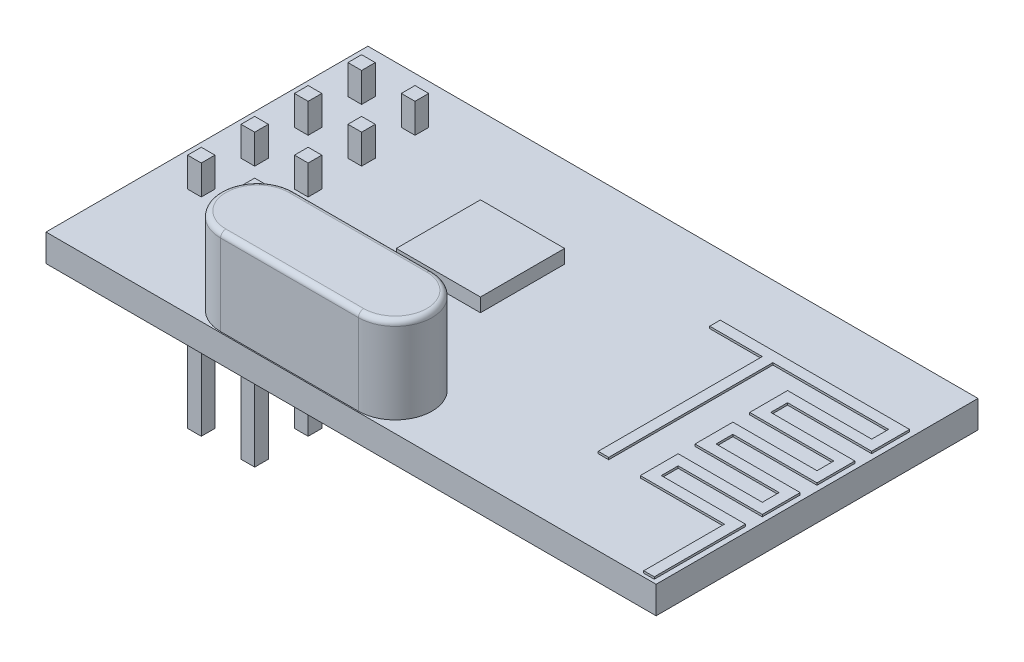
from build123d import *

# Parameters (mm, degrees)
SKETCH1_W                = 29
SKETCH1_H                = 15.3
BOSS_EXTRUDE1_DEPTH      = 1.3
BOSS_EXTRUDE2_DEPTH      = 4.1
SKETCH3_W                = 0.65
SKETCH3_H                = 0.65
BOSS_EXTRUDE3_DEPTH      = 1.4
BOSS_EXTRUDE3_DEPTH_BACK = 10
SKETCH4_W                = 4.99
SKETCH4_H                = 10.07
BOSS_EXTRUDE4_DEPTH      = 2.54
SKETCH5_W                = 4
SKETCH5_H                = 4
BOSS_EXTRUDE5_DEPTH      = 0.65
FILLET1_R                = 0.25
CHAMFER1_SIZE            = 0.15
BOSS_EXTRUDE6_DEPTH      = 0.1


with BuildPart() as part:
    # Sketch1 → Boss-Extrude1 (new body)
    with BuildSketch(Plane(origin=(0, 0, 0), x_dir=(1, 0, 0), z_dir=(0, 1, 0))):
        with Locations((-0.556382979, -0.474734043)):
            Rectangle(SKETCH1_W, SKETCH1_H)
    extrude(amount=BOSS_EXTRUDE1_DEPTH)

    # Sketch2 → Boss-Extrude2 (add)
    with BuildSketch(Plane(origin=(0, 1.3, 0), x_dir=(1, 0, 0), z_dir=(0, 1, 0))):
        with BuildLine():
            Line((-6.806382979, -4.574734043), (-0.256382979, -4.574734043))
            ThreePointArc((-0.256382979, -4.574734043), (1.493617021, -6.324734043), (-0.256382979, -8.074734043))
            Line((-0.256382979, -8.074734043), (-6.806382979, -8.074734043))
            ThreePointArc((-6.806382979, -8.074734043), (-8.556382979, -6.324734043), (-6.806382979, -4.574734043))
        make_face()
    extrude(amount=BOSS_EXTRUDE2_DEPTH)

    # Sketch3 → Boss-Extrude3 (add, two sides)
    with BuildSketch(Plane(origin=(0, 1.3, 0), x_dir=(1, 0, 0), z_dir=(0, 1, 0))) as boss_extrude3_sk:
        with Locations((-13.131382979, 4.950265957)):
            Rectangle(SKETCH3_W, SKETCH3_H)
        with Locations((-10.591382979, 4.950265957)):
            Rectangle(SKETCH3_W, SKETCH3_H)
        with Locations((-10.591382979, 2.410265957)):
            Rectangle(SKETCH3_W, SKETCH3_H)
        with Locations((-10.591382979, -0.129734043)):
            Rectangle(SKETCH3_W, SKETCH3_H)
        with Locations((-10.591382979, -2.669734043)):
            Rectangle(SKETCH3_W, SKETCH3_H)
        with Locations((-13.131382979, 2.410265957)):
            Rectangle(SKETCH3_W, SKETCH3_H)
        with Locations((-13.131382979, -0.129734043)):
            Rectangle(SKETCH3_W, SKETCH3_H)
        with Locations((-13.131382979, -2.669734043)):
            Rectangle(SKETCH3_W, SKETCH3_H)
    extrude(amount=BOSS_EXTRUDE3_DEPTH)
    extrude(boss_extrude3_sk.sketch, amount=-BOSS_EXTRUDE3_DEPTH_BACK)

    # Sketch4 → Boss-Extrude4 (add)
    with BuildSketch(Plane.XZ):
        with Locations((-11.861382979, -1.140265957)):
            Rectangle(SKETCH4_W, SKETCH4_H)
    extrude(amount=BOSS_EXTRUDE4_DEPTH)

    # Sketch5 → Boss-Extrude5 (add)
    with BuildSketch(Plane(origin=(0, 1.3, 0), x_dir=(1, 0, 0), z_dir=(0, 1, 0))):
        with Locations((-3.406382979, 0.875265957)):
            Rectangle(SKETCH5_W, SKETCH5_H)
    extrude(amount=BOSS_EXTRUDE5_DEPTH)

    # Fillet1
    fillet1_edges = [part.edges().sort_by_distance(p)[0] for p in [
        (-8.556382979, 5.4, 6.324734043),
        (-3.531382979, 5.4, 8.074734043),
        (1.493617021, 5.4, 6.324734043),
        (-3.531382979, 5.4, 4.574734043),
    ]]
    fillet(fillet1_edges, radius=FILLET1_R)

    # Chamfer1
    chamfer1_edges = [part.edges().sort_by_distance(p)[0] for p in [
        (-10.591382979, -8.7, 2.344734043),
        (-10.266382979, -8.7, 2.669734043),
        (-10.591382979, -8.7, 2.994734043),
        (-10.916382979, -8.7, 2.669734043),
        (-13.131382979, -8.7, -2.735265957),
        (-12.806382979, -8.7, -2.410265957),
        (-13.131382979, -8.7, -2.085265957),
        (-13.456382979, -8.7, -2.410265957),
        (-13.131382979, -8.7, -0.195265957),
        (-12.806382979, -8.7, 0.129734043),
        (-13.131382979, -8.7, 0.454734043),
        (-13.456382979, -8.7, 0.129734043),
        (-13.131382979, -8.7, 2.344734043),
        (-12.806382979, -8.7, 2.669734043),
        (-13.131382979, -8.7, 2.994734043),
        (-13.456382979, -8.7, 2.669734043),
        (-13.456382979, -8.7, -4.950265957),
        (-13.131382979, -8.7, -5.275265957),
        (-12.806382979, -8.7, -4.950265957),
        (-13.131382979, -8.7, -4.625265957),
        (-10.591382979, -8.7, -5.275265957),
        (-10.266382979, -8.7, -4.950265957),
        (-10.591382979, -8.7, -4.625265957),
        (-10.916382979, -8.7, -4.950265957),
        (-10.591382979, -8.7, -2.735265957),
        (-10.266382979, -8.7, -2.410265957),
        (-10.591382979, -8.7, -2.085265957),
        (-10.916382979, -8.7, -2.410265957),
        (-10.591382979, -8.7, -0.195265957),
        (-10.266382979, -8.7, 0.129734043),
        (-10.591382979, -8.7, 0.454734043),
        (-10.916382979, -8.7, 0.129734043),
    ]]
    chamfer(chamfer1_edges, length=CHAMFER1_SIZE)

    # Sketch6 → Boss-Extrude6 (add)
    with BuildSketch(Plane(origin=(0, 1.3, 0), x_dir=(1, 0, 0), z_dir=(0, 1, 0))):
        Polygon((4.693617021, 4.173262585), (13.693617021, 4.173262585), (13.693617021, 2.373262585), (9.693617021, 2.373262585), (9.693617021, 1.573262585), (13.693617021, 1.573262585), (13.693617021, -0.226737415), (9.693617021, -0.226737415), (9.693617021, -1.026737415), (13.693617021, -1.026737415), (13.693617021, -2.826737415), (9.693617021, -2.826737415), (9.693617021, -3.626737415), (13.693617021, -3.626737415), (13.693617021, -7.962396389), (13.193617021, -7.962396389), (13.193617021, -4.126737415), (9.193617021, -4.126737415), (9.193617021, -2.326737415), (13.193617021, -2.326737415), (13.193617021, -1.526737415), (9.193617021, -1.526737415), (9.193617021, 0.273262585), (13.193617021, 0.273262585), (13.193617021, 1.073262585), (9.193617021, 1.073262585), (9.193617021, 2.873262585), (13.193617021, 2.873262585), (13.193617021, 3.673262585), (7.693617021, 3.673262585), (7.693617021, -4.126737415), (7.193617021, -4.126737415), (7.193617021, 3.671905646), (4.693617021, 3.671905646), align=None)
    extrude(amount=BOSS_EXTRUDE6_DEPTH)


solid = part.part
